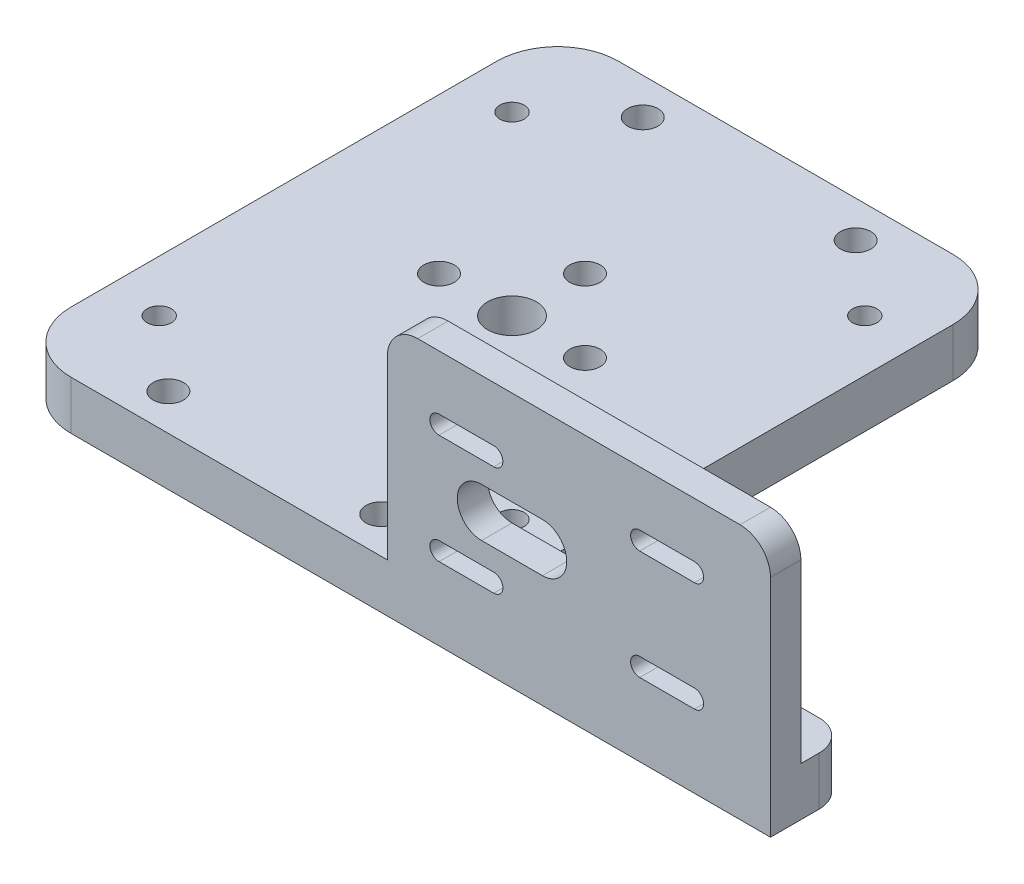
from build123d import *

# Parameters (mm, degrees)
SKETCH1_W               = 75
SKETCH1_H               = 90
SKETCH1_W_2             = 50
SKETCH1_H_2             = 13
BOSS_EXTRUDE1_DEPTH     = 8
SKETCH2_R               = 18
SKETCH2_R_2             = 16
BOSS_EXTRUDE2_DEPTH     = 5
SKETCH3_R               = 2
CUT_EXTRUDE2_DEPTH      = 6
CUT_EXTRUDE2_DEPTH_BACK = 9
FILLET2_R               = 10
FILLET3_R               = 10
FILLET4_R               = 10
CUT_EXTRUDE3_REACH      = 10
SKETCH5_R               = 2.5
SKETCH7_W               = 5
SKETCH7_H               = 34
BOSS_EXTRUDE3_DEPTH     = 63
FILLET5_R               = 5
FILLET6_R               = 5
FILLET7_R               = 5
CUT_EXTRUDE4_REACH      = 92
CUT_EXTRUDE5_REACH      = 44
SKETCH14_R              = 2.5
SKETCH14_R_2            = 4


with BuildPart() as part:
    # Sketch1 → Boss-Extrude1 (new body)
    with BuildSketch(Plane(origin=(0, 0, 0), x_dir=(1, 0, 0), z_dir=(0, 1, 0))):
        with Locations((37.5, -45)):
            Rectangle(SKETCH1_W, SKETCH1_H)
        with Locations((100, -83.5)):
            Rectangle(SKETCH1_W_2, SKETCH1_H_2)
    extrude(amount=BOSS_EXTRUDE1_DEPTH)

    # Sketch2 → Boss-Extrude2 (add)
    with BuildSketch(Plane.XZ):
        with Locations((37.5, 45)):
            Circle(SKETCH2_R)
        with Locations((37.5, 45)):
            Circle(SKETCH2_R_2, mode=Mode.SUBTRACT)
    extrude(amount=BOSS_EXTRUDE2_DEPTH)

    # Sketch3 → Cut-Extrude2 (cut, two sides)
    with BuildSketch(Plane.XZ) as cut_extrude2_sk:
        with Locations((8.5, 74)):
            Circle(SKETCH3_R)
        with Locations((66.5, 74)):
            Circle(SKETCH3_R)
        with Locations((8.5, 16)):
            Circle(SKETCH3_R)
        with Locations((66.5, 16)):
            Circle(SKETCH3_R)
    extrude(amount=CUT_EXTRUDE2_DEPTH, mode=Mode.SUBTRACT)
    extrude(cut_extrude2_sk.sketch, amount=-CUT_EXTRUDE2_DEPTH_BACK, mode=Mode.SUBTRACT)

    # Fillet2
    fillet2_edges = [part.edges().sort_by_distance(p)[0] for p in [
        (0, 4, 0),
    ]]
    fillet(fillet2_edges, radius=FILLET2_R)

    # Fillet3
    fillet3_edges = [part.edges().sort_by_distance(p)[0] for p in [
        (0, 4, 90),
    ]]
    fillet(fillet3_edges, radius=FILLET3_R)

    # Fillet4
    fillet4_edges = [part.edges().sort_by_distance(p)[0] for p in [
        (75, 4, 0),
    ]]
    fillet(fillet4_edges, radius=FILLET4_R)

    # Sketch5 → Cut-Extrude3 (cut, up to next)
    with BuildSketch(Plane.XZ, mode=Mode.PRIVATE) as cut_extrude3_sk1:
        with Locations((55, 6)):
            Circle(SKETCH5_R)
    cut_extrude3_tool1 = extrude(cut_extrude3_sk1.sketch, amount=-CUT_EXTRUDE3_REACH, mode=Mode.PRIVATE) & part.part
    add(cut_extrude3_tool1.solids().sort_by_distance((55, 0, 6))[0], mode=Mode.SUBTRACT)
    # Sketch5 → Cut-Extrude3 (cut, up to next)
    with BuildSketch(Plane.XZ, mode=Mode.PRIVATE) as cut_extrude3_sk2:
        with Locations((20, 84)):
            Circle(SKETCH5_R)
    cut_extrude3_tool2 = extrude(cut_extrude3_sk2.sketch, amount=-CUT_EXTRUDE3_REACH, mode=Mode.PRIVATE) & part.part
    add(cut_extrude3_tool2.solids().sort_by_distance((20, 0, 84))[0], mode=Mode.SUBTRACT)
    # Sketch5 → Cut-Extrude3 (cut, up to next)
    with BuildSketch(Plane.XZ, mode=Mode.PRIVATE) as cut_extrude3_sk3:
        with Locations((55, 84)):
            Circle(SKETCH5_R)
    cut_extrude3_tool3 = extrude(cut_extrude3_sk3.sketch, amount=-CUT_EXTRUDE3_REACH, mode=Mode.PRIVATE) & part.part
    add(cut_extrude3_tool3.solids().sort_by_distance((55, 0, 84))[0], mode=Mode.SUBTRACT)
    # Sketch5 → Cut-Extrude3 (cut, up to next)
    with BuildSketch(Plane.XZ, mode=Mode.PRIVATE) as cut_extrude3_sk4:
        with Locations((20, 6)):
            Circle(SKETCH5_R)
    cut_extrude3_tool4 = extrude(cut_extrude3_sk4.sketch, amount=-CUT_EXTRUDE3_REACH, mode=Mode.PRIVATE) & part.part
    add(cut_extrude3_tool4.solids().sort_by_distance((20, 0, 6))[0], mode=Mode.SUBTRACT)

    # Sketch7 → Boss-Extrude3 (add)
    with BuildSketch(Plane(origin=(125, 0, 0), x_dir=(0, 0, -1), z_dir=(1, 0, 0))):
        with Locations((-87.5, 25)):
            Rectangle(SKETCH7_W, SKETCH7_H)
    extrude(amount=-BOSS_EXTRUDE3_DEPTH)

    # Fillet5
    fillet5_edges = [part.edges().sort_by_distance(p)[0] for p in [
        (125, 42, 87.5),
    ]]
    fillet(fillet5_edges, radius=FILLET5_R)

    # Fillet6
    fillet6_edges = [part.edges().sort_by_distance(p)[0] for p in [
        (125, 4, 77),
    ]]
    fillet(fillet6_edges, radius=FILLET6_R)

    # Fillet7
    fillet7_edges = [part.edges().sort_by_distance(p)[0] for p in [
        (62, 42, 87.5),
    ]]
    fillet(fillet7_edges, radius=FILLET7_R)

    # Sketch12 → Cut-Extrude4 (cut, up to next)
    with BuildSketch(Plane.XY.offset(90), mode=Mode.PRIVATE) as cut_extrude4_sk1:
        with BuildLine():
            Line((77.5, 26.5), (87.5, 26.5))
            ThreePointArc((87.5, 26.5), (91.5, 22.5), (87.5, 18.5))
            Line((87.5, 18.5), (77.5, 18.5))
            ThreePointArc((77.5, 18.5), (73.5, 22.5), (77.5, 26.5))
        make_face()
    cut_extrude4_tool1 = extrude(cut_extrude4_sk1.sketch, amount=-CUT_EXTRUDE4_REACH, mode=Mode.PRIVATE) & part.part
    add(cut_extrude4_tool1.solids().sort_by_distance((82.5, 22.5, 90))[0], mode=Mode.SUBTRACT)
    # Sketch12 → Cut-Extrude4 (cut, up to next)
    with BuildSketch(Plane.XY.offset(90), mode=Mode.PRIVATE) as cut_extrude4_sk2:
        with BuildLine():
            Line((70.5, 33), (79.5, 33))
            ThreePointArc((79.5, 33), (81, 31.5), (79.5, 30))
            Line((79.5, 30), (70.5, 30))
            ThreePointArc((70.5, 30), (69, 31.5), (70.5, 33))
        make_face()
    cut_extrude4_tool2 = extrude(cut_extrude4_sk2.sketch, amount=-CUT_EXTRUDE4_REACH, mode=Mode.PRIVATE) & part.part
    add(cut_extrude4_tool2.solids().sort_by_distance((75, 31.5, 90))[0], mode=Mode.SUBTRACT)
    # Sketch12 → Cut-Extrude4 (cut, up to next)
    with BuildSketch(Plane.XY.offset(90), mode=Mode.PRIVATE) as cut_extrude4_sk3:
        with BuildLine():
            Line((70.5, 12), (79.5, 12))
            ThreePointArc((79.5, 12), (81, 13.5), (79.5, 15))
            Line((79.5, 15), (70.5, 15))
            ThreePointArc((70.5, 15), (69, 13.5), (70.5, 12))
        make_face()
    cut_extrude4_tool3 = extrude(cut_extrude4_sk3.sketch, amount=-CUT_EXTRUDE4_REACH, mode=Mode.PRIVATE) & part.part
    add(cut_extrude4_tool3.solids().sort_by_distance((75, 13.5, 90))[0], mode=Mode.SUBTRACT)
    # Sketch12 → Cut-Extrude4 (cut, up to next)
    with BuildSketch(Plane.XY.offset(90), mode=Mode.PRIVATE) as cut_extrude4_sk4:
        with BuildLine():
            Line((103.5, 33), (112.5, 33))
            ThreePointArc((112.5, 33), (114, 31.5), (112.5, 30))
            Line((112.5, 30), (103.5, 30))
            ThreePointArc((103.5, 30), (102, 31.5), (103.5, 33))
        make_face()
    cut_extrude4_tool4 = extrude(cut_extrude4_sk4.sketch, amount=-CUT_EXTRUDE4_REACH, mode=Mode.PRIVATE) & part.part
    add(cut_extrude4_tool4.solids().sort_by_distance((108, 31.5, 90))[0], mode=Mode.SUBTRACT)
    # Sketch12 → Cut-Extrude4 (cut, up to next)
    with BuildSketch(Plane.XY.offset(90), mode=Mode.PRIVATE) as cut_extrude4_sk5:
        with BuildLine():
            Line((103.5, 12), (112.5, 12))
            ThreePointArc((112.5, 12), (114, 13.5), (112.5, 15))
            Line((112.5, 15), (103.5, 15))
            ThreePointArc((103.5, 15), (102, 13.5), (103.5, 12))
        make_face()
    cut_extrude4_tool5 = extrude(cut_extrude4_sk5.sketch, amount=-CUT_EXTRUDE4_REACH, mode=Mode.PRIVATE) & part.part
    add(cut_extrude4_tool5.solids().sort_by_distance((108, 13.5, 90))[0], mode=Mode.SUBTRACT)

    # Sketch14 → Cut-Extrude5 (cut, up to next)
    with BuildSketch(Plane.XZ, mode=Mode.PRIVATE) as cut_extrude5_sk1:
        with Locations((37.5, 57)):
            Circle(SKETCH14_R)
    cut_extrude5_tool1 = extrude(cut_extrude5_sk1.sketch, amount=-CUT_EXTRUDE5_REACH, mode=Mode.PRIVATE) & part.part
    add(cut_extrude5_tool1.solids().sort_by_distance((37.5, 0, 57))[0], mode=Mode.SUBTRACT)
    # Sketch14 → Cut-Extrude5 (cut, up to next)
    with BuildSketch(Plane.XZ, mode=Mode.PRIVATE) as cut_extrude5_sk2:
        with Locations((37.5, 45)):
            Circle(SKETCH14_R_2)
    cut_extrude5_tool2 = extrude(cut_extrude5_sk2.sketch, amount=-CUT_EXTRUDE5_REACH, mode=Mode.PRIVATE) & part.part
    add(cut_extrude5_tool2.solids().sort_by_distance((37.5, 0, 45))[0], mode=Mode.SUBTRACT)
    # Sketch14 → Cut-Extrude5 (cut, up to next)
    with BuildSketch(Plane.XZ, mode=Mode.PRIVATE) as cut_extrude5_sk3:
        with Locations((49.5, 45)):
            Circle(SKETCH14_R)
    cut_extrude5_tool3 = extrude(cut_extrude5_sk3.sketch, amount=-CUT_EXTRUDE5_REACH, mode=Mode.PRIVATE) & part.part
    add(cut_extrude5_tool3.solids().sort_by_distance((49.5, 0, 45))[0], mode=Mode.SUBTRACT)
    # Sketch14 → Cut-Extrude5 (cut, up to next)
    with BuildSketch(Plane.XZ, mode=Mode.PRIVATE) as cut_extrude5_sk4:
        with Locations((37.5, 33)):
            Circle(SKETCH14_R)
    cut_extrude5_tool4 = extrude(cut_extrude5_sk4.sketch, amount=-CUT_EXTRUDE5_REACH, mode=Mode.PRIVATE) & part.part
    add(cut_extrude5_tool4.solids().sort_by_distance((37.5, 0, 33))[0], mode=Mode.SUBTRACT)
    # Sketch14 → Cut-Extrude5 (cut, up to next)
    with BuildSketch(Plane.XZ, mode=Mode.PRIVATE) as cut_extrude5_sk5:
        with Locations((25.5, 45)):
            Circle(SKETCH14_R)
    cut_extrude5_tool5 = extrude(cut_extrude5_sk5.sketch, amount=-CUT_EXTRUDE5_REACH, mode=Mode.PRIVATE) & part.part
    add(cut_extrude5_tool5.solids().sort_by_distance((25.5, 0, 45))[0], mode=Mode.SUBTRACT)


solid = part.part
